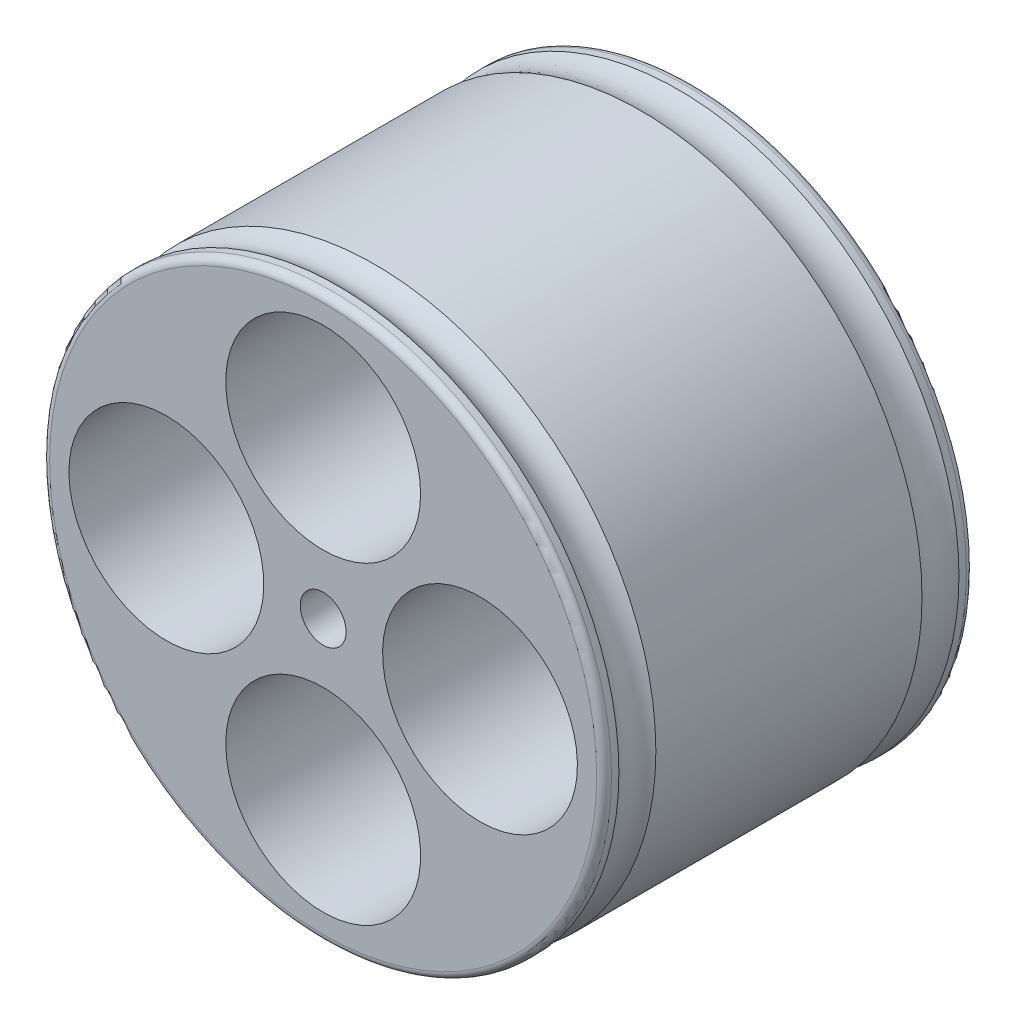
from build123d import *

# Parameters (mm, degrees)
SKETCH1_R           = 19
BOSS_EXTRUDE1_DEPTH = 25
FILLET1_R           = 0.5
SKETCH3_R           = 1.55
CUT_EXTRUDE1_DEPTH  = 26.0000001
SKETCH4_R           = 6.58897104
CUT_EXTRUDE2_DEPTH  = 26.0000001
CIRPATTERN1_COUNT   = 4


with BuildPart() as part:
    # Sketch1 → Boss-Extrude1 (new body)
    with BuildSketch(Plane.XY):
        Circle(SKETCH1_R)
    extrude(amount=BOSS_EXTRUDE1_DEPTH)

    # Sketch2 → Cut-Revolve1 (revolve, cut)
    with BuildSketch(Plane(origin=(0, 0, 0), x_dir=(0, 0, -1), z_dir=(1, 0, 0))):
        with BuildLine():
            Line((-24, 19), (-21.5, 19))
            ThreePointArc((-21.5, 19), (-22.75, 18.5), (-24, 19))
        make_face()
        with BuildLine():
            Line((-3.5, 19), (-1, 19))
            ThreePointArc((-1, 19), (-2.25, 18.7), (-3.5, 19))
        make_face()
    revolve(axis=Axis((0, 0, 8.4), (0, 0, -1)), mode=Mode.SUBTRACT)

    # Fillet1
    fillet1_edges = [part.edges().sort_by_distance(p)[0] for p in [
        (-19, 0, 0),
        (-19, 0, 25),
    ]]
    fillet(fillet1_edges, radius=FILLET1_R)

    # Sketch3 → Cut-Extrude1 (cut, through all)
    with BuildSketch(Plane.XY.offset(25)):
        Circle(SKETCH3_R)
    extrude(amount=-CUT_EXTRUDE1_DEPTH, mode=Mode.SUBTRACT)

    # Sketch4 → Cut-Extrude2 (cut, through all)
    with BuildSketch(Plane.XY.offset(25)):
        with Locations((0, 10.60646011)):
            Circle(SKETCH4_R)
    cut_extrude2 = extrude(amount=-CUT_EXTRUDE2_DEPTH, mode=Mode.SUBTRACT)

    # CirPattern1: Cut-Extrude2 ×4 about axis
    cirpattern1_axis = Axis((0, 0, 0), (0, 0, 1))
    for i in range(1, CIRPATTERN1_COUNT):
        add(cut_extrude2.rotate(cirpattern1_axis, i * 360 / CIRPATTERN1_COUNT), mode=Mode.SUBTRACT)


solid = part.part
